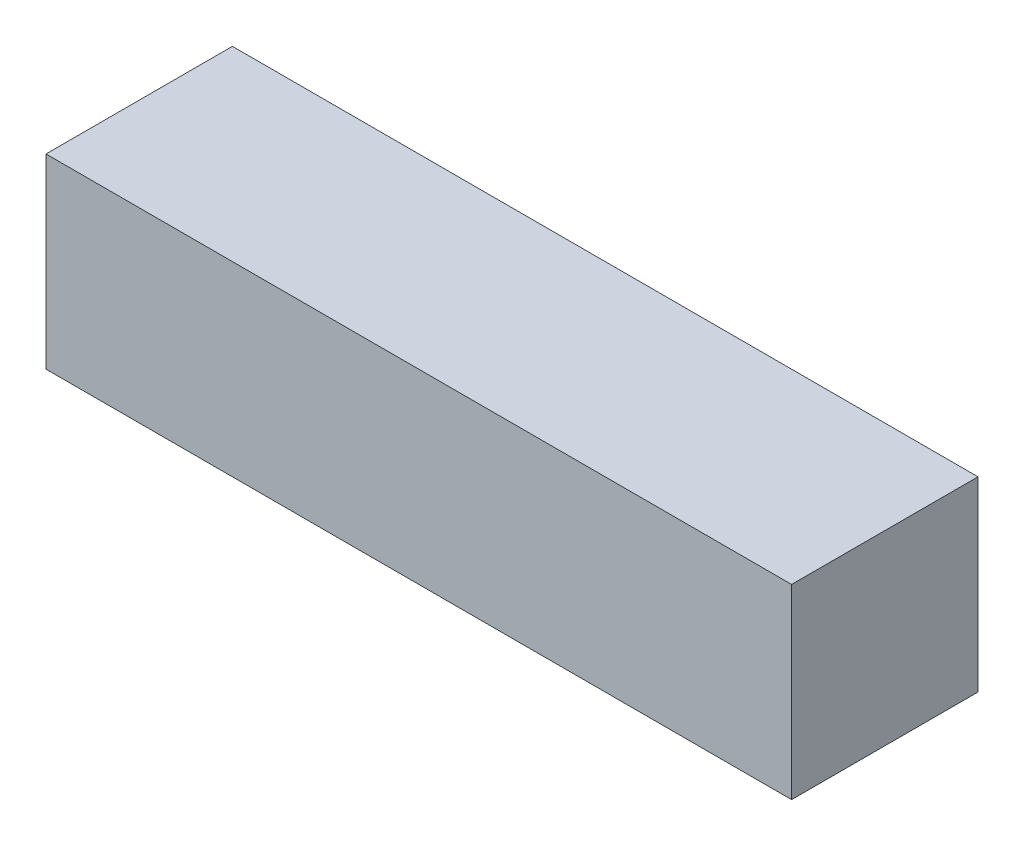
from build123d import *

# Parameters (mm, degrees)
SKETCH1_W           = 9.525
SKETCH1_H           = 9.525
BOSS_EXTRUDE1_DEPTH = 19.05


with BuildPart() as part:
    # Sketch1 → Boss-Extrude1 (new body, symmetric)
    with BuildSketch(Plane(origin=(0, 0, 0), x_dir=(0, 0, -1), z_dir=(1, 0, 0))):
        Rectangle(SKETCH1_W, SKETCH1_H)
    extrude(amount=BOSS_EXTRUDE1_DEPTH, both=True)


solid = part.part
